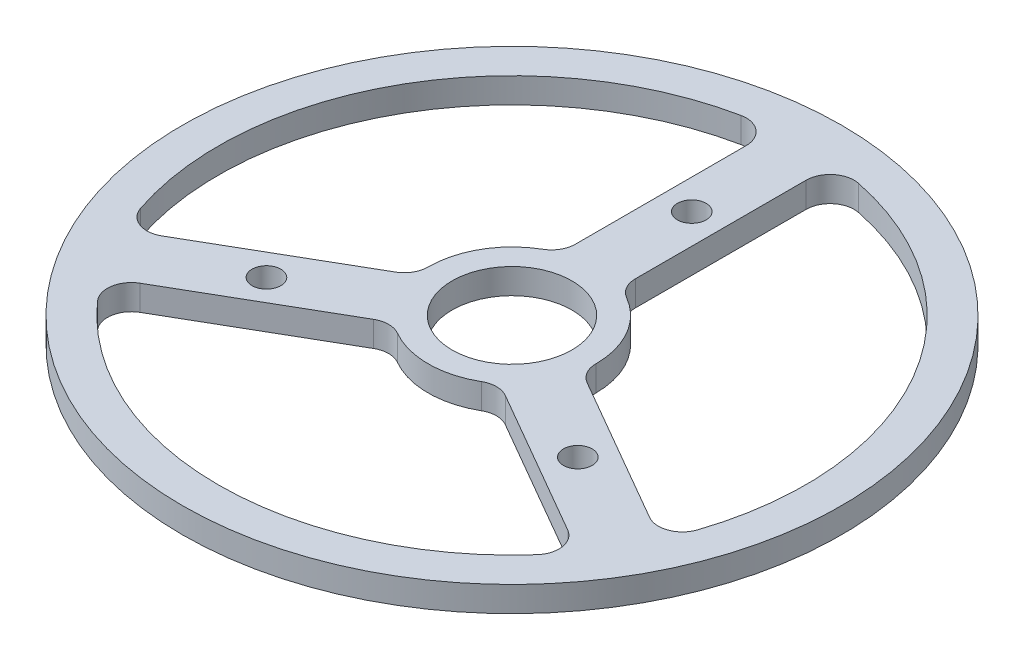
from build123d import *

# Parameters (mm, degrees)
CROQUIS1_R              = 27.5
SALIENTE_EXTRUIR1_DEPTH = 2.11
CROQUIS2_R              = 1.2
CROQUIS2_R_2            = 5
CORTAR_EXTRUIR1_DEPTH   = 3.11
REDONDEO1_R             = 2


with BuildPart() as part:
    # Croquis1 → Saliente-Extruir1 (new body)
    with BuildSketch(Plane(origin=(0, 0, 0), x_dir=(1, 0, 0), z_dir=(0, 1, 0))):
        Circle(CROQUIS1_R)
    extrude(amount=SALIENTE_EXTRUIR1_DEPTH)

    # Croquis2 → Cortar-Extruir1 (cut, through all)
    with BuildSketch(Plane(origin=(0, 2.11, 0), x_dir=(1, 0, 0), z_dir=(0, 1, 0))):
        with Locations((0, 15)):
            Circle(CROQUIS2_R)
        with Locations((12.990381057, -7.5)):
            Circle(CROQUIS2_R)
        with Locations((-12.990381057, -7.5)):
            Circle(CROQUIS2_R)
        Circle(CROQUIS2_R_2)
        with BuildLine():
            Line((-2.5, 6.538348415), (-2.5, 24.372115214))
            ThreePointArc((-2.5, 24.372115214), (-21.217622393, 12.25), (-22.356870919, -10.020994097))
            Line((-22.356870919, -10.020994097), (-6.912375826, -1.104110698))
            ThreePointArc((-6.912375826, -1.104110698), (-6.062177826, 3.5), (-2.5, 6.538348415))
        make_face()
        with BuildLine():
            Line((2.5, 6.538348415), (2.5, 24.372115214))
            ThreePointArc((2.5, 24.372115214), (21.217622393, 12.25), (22.356870919, -10.020994097))
            Line((22.356870919, -10.020994097), (6.912375826, -1.104110698))
            ThreePointArc((6.912375826, -1.104110698), (6.062177826, 3.5), (2.5, 6.538348415))
        make_face()
        with BuildLine():
            Line((4.412375826, -5.434237717), (19.856870919, -14.351121116))
            ThreePointArc((19.856870919, -14.351121116), (0, -24.5), (-19.856870919, -14.351121116))
            Line((-19.856870919, -14.351121116), (-4.412375826, -5.434237717))
            ThreePointArc((-4.412375826, -5.434237717), (0, -7), (4.412375826, -5.434237717))
        make_face()
    extrude(amount=-CORTAR_EXTRUIR1_DEPTH, mode=Mode.SUBTRACT)

    # Redondeo1
    redondeo1_edges = [part.edges().sort_by_distance(p)[0] for p in [
        (-2.5, 1.055, -6.538348415),
        (-6.912375826, 1.055, 1.104110698),
        (-22.356870919, 1.055, 10.020994097),
        (-2.5, 1.055, -24.372115214),
        (-4.412375826, 1.055, 5.434237717),
        (4.412375826, 1.055, 5.434237717),
        (19.856870919, 1.055, 14.351121116),
        (-19.856870919, 1.055, 14.351121116),
        (6.912375826, 1.055, 1.104110698),
        (2.5, 1.055, -6.538348415),
        (2.5, 1.055, -24.372115214),
        (22.356870919, 1.055, 10.020994097),
    ]]
    fillet(redondeo1_edges, radius=REDONDEO1_R)


solid = part.part
